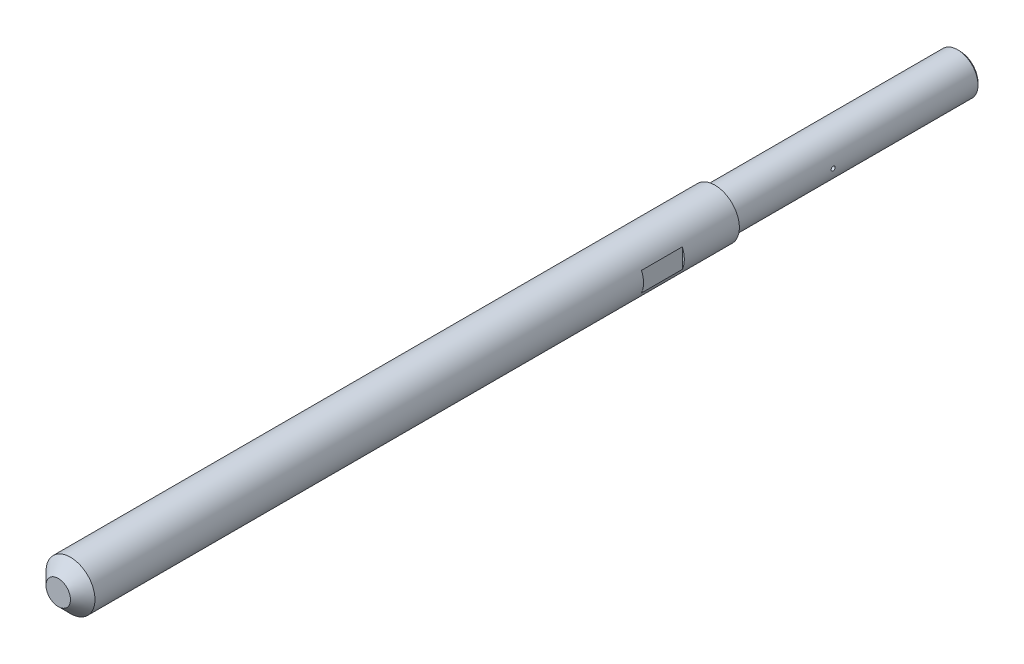
from build123d import *

# Parameters (mm, degrees)
SKETCH1_R               = 5
BOSS_EXTRUDE1_DEPTH     = 60
SKETCH2_R               = 6
BOSS_EXTRUDE2_DEPTH     = 161
SKETCH3_R               = 0.5
CUT_EXTRUDE1_DEPTH      = 1.5
CUT_EXTRUDE1_DEPTH_BACK = 12.5
SKETCH4_W               = 10
SKETCH4_H               = 4.936159812
CUT_EXTRUDE2_DEPTH      = 1.5
M5_TAPPED_HOLE1_D       = 4.2
M5_TAPPED_HOLE1_DEPTH   = 10
M5_TAPPED_HOLE1_TIP     = 1.2618073
CHAMFER1_SIZE           = 3
CHAMFER2_SIZE           = 0.5
SKETCH8_W               = 5
SKETCH8_H               = 30
CUT_EXTRUDE3_DEPTH      = 161


with BuildPart() as part:
    # Sketch1 → Boss-Extrude1 (new body)
    with BuildSketch(Plane.XY):
        Circle(SKETCH1_R)
    extrude(amount=BOSS_EXTRUDE1_DEPTH)

    # Sketch2 → Boss-Extrude2 (add)
    with BuildSketch(Plane.XY.offset(60)):
        Circle(SKETCH2_R)
    extrude(amount=BOSS_EXTRUDE2_DEPTH)

    # Sketch3 → Cut-Extrude1 (cut, two sides)
    with BuildSketch(Plane(origin=(5.5, 0, 0), x_dir=(0, 0, -1), z_dir=(1, 0, 0))) as cut_extrude1_sk:
        with Locations((-36, 0)):
            Circle(SKETCH3_R)
    extrude(amount=CUT_EXTRUDE1_DEPTH, mode=Mode.SUBTRACT)
    extrude(cut_extrude1_sk.sketch, amount=-CUT_EXTRUDE1_DEPTH_BACK, mode=Mode.SUBTRACT)

    # Sketch4 → Cut-Extrude2 (cut, through all)
    with BuildSketch(Plane(origin=(5.5, 0, 0), x_dir=(0, 0, -1), z_dir=(1, 0, 0))):
        with Locations((-78.5, 0)):
            Rectangle(SKETCH4_W, SKETCH4_H)
    extrude(amount=CUT_EXTRUDE2_DEPTH, mode=Mode.SUBTRACT)

    # M5 Tapped Hole1
    with Locations(Plane(origin=(0, 0, 0), x_dir=(-1, 0, 0), z_dir=(0, 0, -1))):
        with Locations((0, 0)):
            Hole(M5_TAPPED_HOLE1_D / 2, depth=M5_TAPPED_HOLE1_DEPTH)
            with Locations((0, 0, -(M5_TAPPED_HOLE1_DEPTH + M5_TAPPED_HOLE1_TIP / 2))):  # 118° drill point
                Cone(0, M5_TAPPED_HOLE1_D / 2, M5_TAPPED_HOLE1_TIP, mode=Mode.SUBTRACT)

    # Chamfer1
    chamfer1_edges = [part.edges().sort_by_distance(p)[0] for p in [
        (-6, 0, 221),
    ]]
    chamfer(chamfer1_edges, length=CHAMFER1_SIZE)

    # Chamfer2
    chamfer2_edges = [part.edges().sort_by_distance(p)[0] for p in [
        (-5, 0, 0),
    ]]
    chamfer(chamfer2_edges, length=CHAMFER2_SIZE)

    # Sketch8 → Cut-Extrude3 (cut)
    with BuildSketch(Plane(origin=(0, -5.5, 0), x_dir=(1, 0, 0), z_dir=(0, 1, 0))):
        with Locations((-0.510877728, -80)):
            Rectangle(SKETCH8_W, SKETCH8_H)
    extrude(amount=-CUT_EXTRUDE3_DEPTH, mode=Mode.SUBTRACT)


solid = part.part
